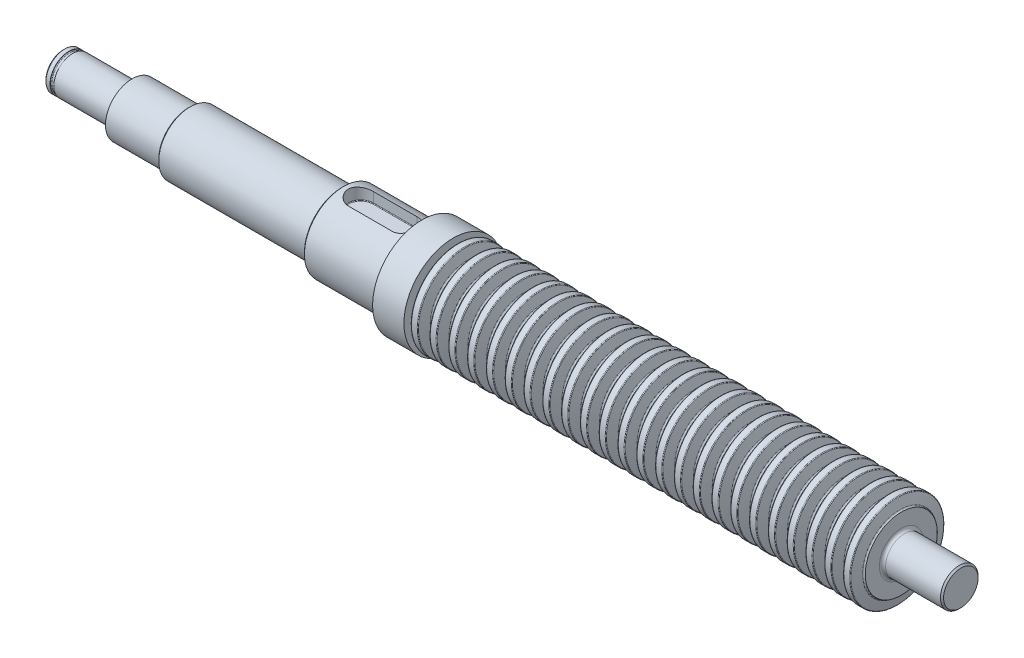
from build123d import *

# Parameters (mm, degrees)
PATTERN_LINEAR_1_COUNT = 24
PATTERN_LINEAR_1_PITCH = 6
FILLET_3_R             = 1
CHAMFER_1_SIZE         = 0.5
FILLET_6_R             = 0.5
CUT_EXTRUDE_2200_REACH = 26.25
CUT_EXTRUDE_START      = 8.5
FILLET_5_R             = 0.2


with BuildPart() as part:
    # Sketch 1 → Revolve 1 (revolve)
    with BuildSketch(Plane.XY):
        Polygon((-119.5, 0), (-119.5, 6), (-97.5, 6), (-97.5, 8.5), (-79.5, 8.5), (-79.5, 10.00005), (-30.5, 10.00005), (-30.5, 12.5), (-5, 12.5), (-5, 15.75), (5, 15.75), (5, 11.5), (148, 11.5), (148, 6), (167, 6), (167, 0), align=None)
    revolve(axis=Axis((167, 0, 0), (1, 0, 0)))

    # Sketch 2_2 → Revolve 2 (revolve)
    with BuildSketch(Plane.XY):
        with BuildLine():
            Line((6.673755536, 15), (8.486244464, 15))
            ThreePointArc((8.486244464, 15), (8.638434822, 14.948338335), (8.727725921, 14.814704761))
            Line((8.727725921, 14.814704761), (9.516598966, 11.870590477))
            ThreePointArc((9.516598966, 11.870590477), (9.695181164, 11.60332333), (9.999561879, 11.5))
            Line((9.999561879, 11.5), (5.160438121, 11.5))
            ThreePointArc((5.160438121, 11.5), (5.464818836, 11.60332333), (5.643401034, 11.870590477))
            Line((5.643401034, 11.870590477), (6.432274079, 14.814704761))
            ThreePointArc((6.432274079, 14.814704761), (6.521565178, 14.948338335), (6.673755536, 15))
        make_face()
    revolve_2 = revolve(axis=Axis((0, 0, 0), (1, 0, 0)))

    # Pattern Linear 1: Revolve 2 ×24
    with Locations(*[(i * PATTERN_LINEAR_1_PITCH, 0, 0) for i in range(1, PATTERN_LINEAR_1_COUNT)]):
        add(revolve_2)

    # Fillet 3
    fillet_3_edges = [part.edges().sort_by_distance(p)[0] for p in [
        (148, -6, 0),
        (-5, -12.5, 0),
        (-30.5, -10.00005, 0),
        (-97.5, -6, 0),
    ]]
    fillet(fillet_3_edges, radius=FILLET_3_R)

    # Chamfer 1
    chamfer_1_edges = [part.edges().sort_by_distance(p)[0] for p in [
        (-119.5, -6, 0),
        (167, -6, 0),
        (-30.5, -12.5, 0),
        (-79.5, -10.00005, 0),
    ]]
    chamfer(chamfer_1_edges, length=CHAMFER_1_SIZE)

    # Fillet 6
    fillet_6_edges = [part.edges().sort_by_distance(p)[0] for p in [
        (-79.5, -8.5, 0),
    ]]
    fillet(fillet_6_edges, radius=FILLET_6_R)

    # Sketch 6 → DIN 6799 - 10_ _ _ _ _1 (revolve, cut)
    with BuildSketch(Plane(origin=(167.5, 0, 0), x_dir=(0, 0, 1), z_dir=(0, -1, 0))):
        with BuildLine():
            Line((5.9, 284), (7, 284))
            Line((7, 284), (7, 285.2))
            Line((7, 285.2), (5.9, 285.2))
            ThreePointArc((5.9, 285.2), (5.723223305, 285.126776695), (5.65, 284.95))
            Line((5.65, 284.95), (5.65, 284.25))
            ThreePointArc((5.65, 284.25), (5.723223305, 284.073223305), (5.9, 284))
        make_face()
    revolve(axis=Axis((167, 0, 0), (-1, 0, 0)), mode=Mode.SUBTRACT)

    # Sketch 7 → Cut-Extrude 2200 (cut, up to next)
    with BuildSketch(Plane(origin=(0, 0, 0), x_dir=(1, 0, 0), z_dir=(0, 1, 0)).offset(CUT_EXTRUDE_START), mode=Mode.PRIVATE) as cut_extrude_2200_sk1:
        with BuildLine():
            Line((-24.5, -4), (-10.5, -4))
            ThreePointArc((-10.5, -4), (-6.5, 0), (-10.5, 4))
            Line((-10.5, 4), (-24.5, 4))
            ThreePointArc((-24.5, 4), (-28.5, 0), (-24.5, -4))
        make_face()
    cut_extrude_2200_tool1 = extrude(cut_extrude_2200_sk1.sketch, amount=CUT_EXTRUDE_2200_REACH, mode=Mode.PRIVATE) & part.part
    add(cut_extrude_2200_tool1.solids().sort_by_distance((-17.5, 8.5, 0))[0], mode=Mode.SUBTRACT)

    # Fillet 5
    fillet_5_edges = [part.edges().sort_by_distance(p)[0] for p in [
        (-17.5, 8.5, 4),
        (-28.5, 8.5, 0),
        (-17.5, 8.5, -4),
        (-6.5, 8.5, 0),
    ]]
    fillet(fillet_5_edges, radius=FILLET_5_R)


solid = part.part
